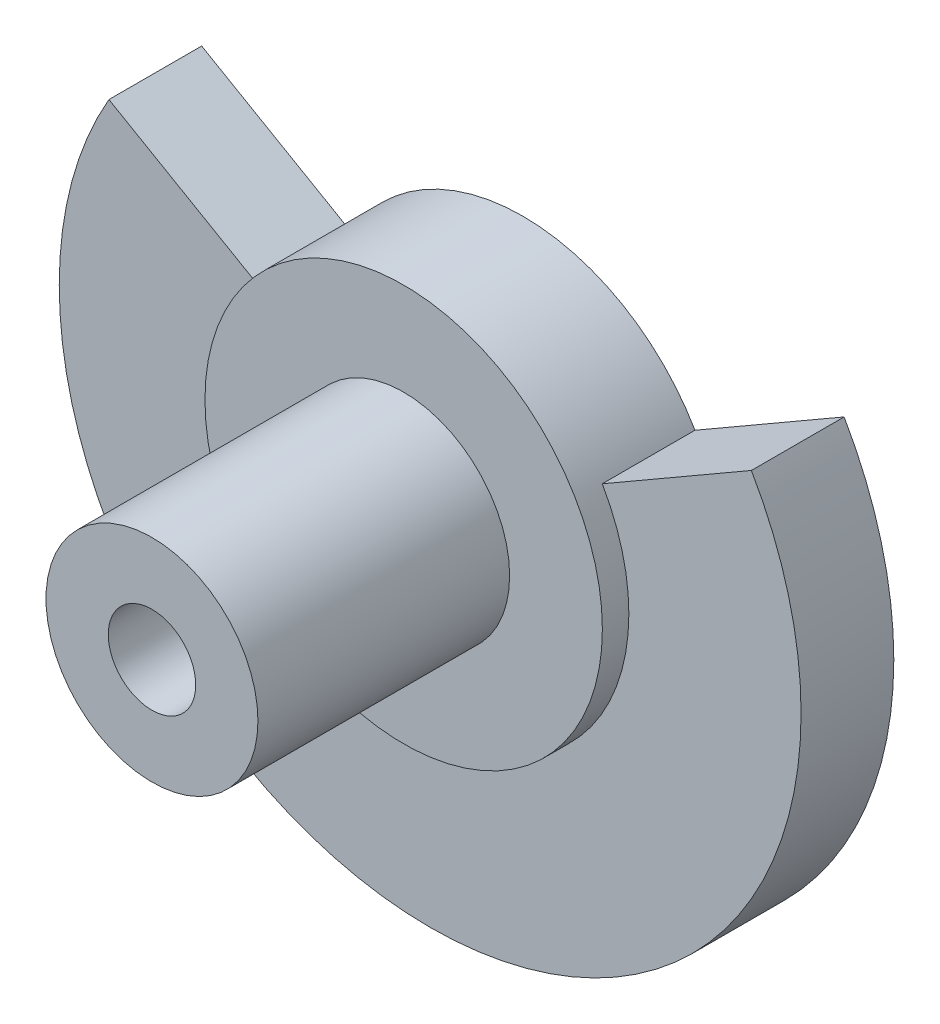
from build123d import *

# Parameters (mm, degrees)
SKETCH1_R           = 14
SKETCH1_R_2         = 1.65
BOSS_EXTRUDE1_DEPTH = 14
SKETCH2_R           = 14
SKETCH2_R_2         = 4
CUT_EXTRUDE1_DEPTH  = 9.5
SKETCH3_R           = 14
SKETCH3_R_2         = 7.5
CUT_EXTRUDE2_DEPTH  = 1
CUT_EXTRUDE3_DEPTH  = 4.5


with BuildPart() as part:
    # Sketch1 → Boss-Extrude1 (new body)
    with BuildSketch(Plane.XY):
        Circle(SKETCH1_R)
        Circle(SKETCH1_R_2, mode=Mode.SUBTRACT)
    extrude(amount=BOSS_EXTRUDE1_DEPTH)

    # Sketch2 → Cut-Extrude1 (cut)
    with BuildSketch(Plane.XY.offset(14)):
        Circle(SKETCH2_R)
        Circle(SKETCH2_R_2, mode=Mode.SUBTRACT)
    extrude(amount=-CUT_EXTRUDE1_DEPTH, mode=Mode.SUBTRACT)

    # Sketch3 → Cut-Extrude2 (cut)
    with BuildSketch(Plane.XY.offset(4.5)):
        Circle(SKETCH3_R)
        Circle(SKETCH3_R_2, mode=Mode.SUBTRACT)
    extrude(amount=-CUT_EXTRUDE2_DEPTH, mode=Mode.SUBTRACT)

    # Sketch4 → Cut-Extrude3 (cut, through all)
    with BuildSketch(Plane.XY.offset(3.5)):
        with BuildLine():
            Line((6.495190528, 3.75), (12.124355653, 7))
            ThreePointArc((12.124355653, 7), (0, 14), (-12.124355653, 7))
            Line((-12.124355653, 7), (-6.495190528, 3.75))
            ThreePointArc((-6.495190528, 3.75), (0, 7.5), (6.495190528, 3.75))
        make_face()
    extrude(amount=-CUT_EXTRUDE3_DEPTH, mode=Mode.SUBTRACT)


solid = part.part
